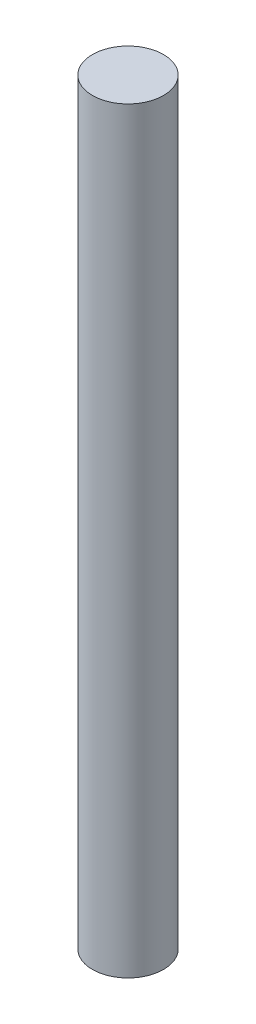
from build123d import *

# Parameters (mm, degrees)
SKETCH1_R           = 4
BOSS_EXTRUDE1_DEPTH = 95
SKETCH2_R           = 4
CUT_EXTRUDE1_DEPTH  = 9.74


with BuildPart() as part:
    # Sketch1 → Boss-Extrude1 (new body)
    with BuildSketch(Plane(origin=(0, 0, 0), x_dir=(1, 0, 0), z_dir=(0, 1, 0))):
        Circle(SKETCH1_R)
    extrude(amount=BOSS_EXTRUDE1_DEPTH)

    # Sketch2 → Cut-Extrude1 (cut)
    with BuildSketch(Plane(origin=(0, 95, 0), x_dir=(1, 0, 0), z_dir=(0, 1, 0))):
        Circle(SKETCH2_R)
    extrude(amount=-CUT_EXTRUDE1_DEPTH, mode=Mode.SUBTRACT)


solid = part.part
